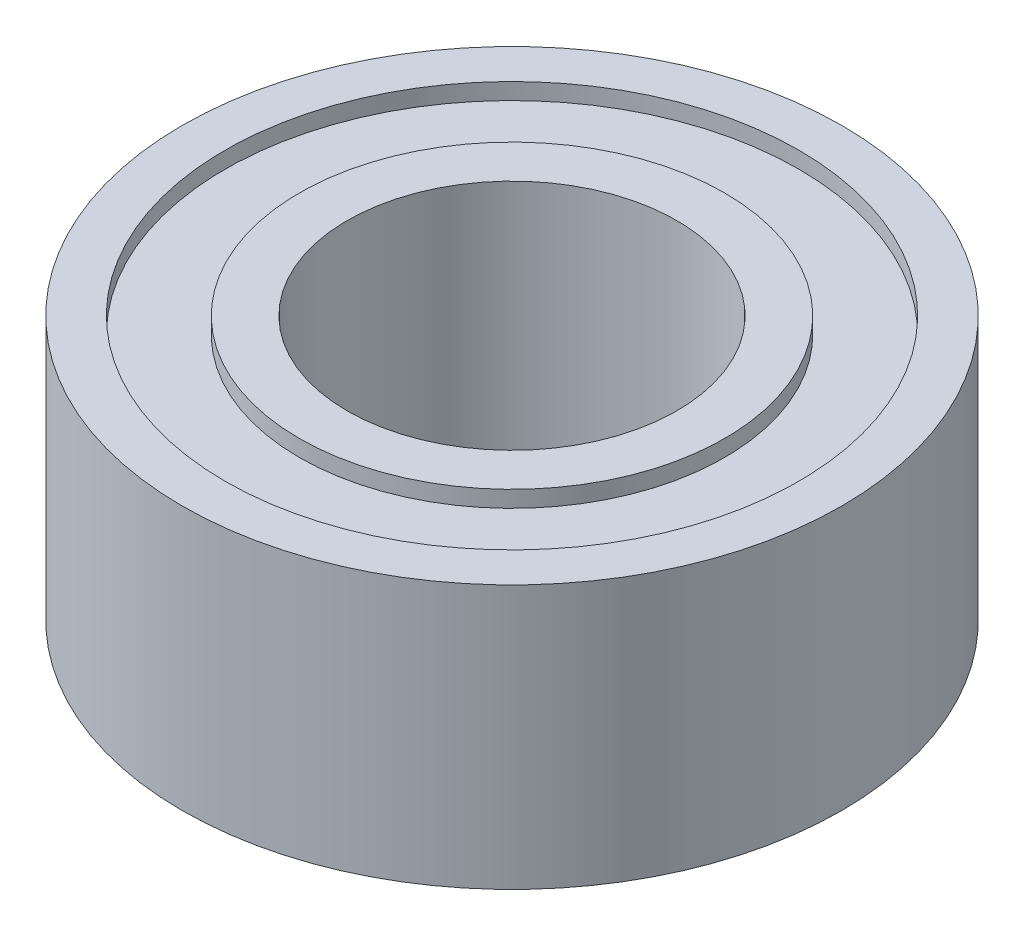
from build123d import *

# Parameters (mm, degrees)
SKETCH1_R           = 5
SKETCH1_R_2         = 2.5
BOSS_EXTRUDE1_DEPTH = 4
SKETCH2_R           = 4.35
SKETCH2_R_2         = 3.225
CUT_EXTRUDE1_DEPTH  = 0.25
SKETCH3_R           = 4.35
SKETCH3_R_2         = 3.225
CUT_EXTRUDE2_DEPTH  = 0.25


with BuildPart() as part:
    # Sketch1 → Boss-Extrude1 (new body)
    with BuildSketch(Plane(origin=(0, 0, 0), x_dir=(1, 0, 0), z_dir=(0, 1, 0))):
        Circle(SKETCH1_R)
        Circle(SKETCH1_R_2, mode=Mode.SUBTRACT)
    extrude(amount=BOSS_EXTRUDE1_DEPTH)

    # Sketch2 → Cut-Extrude1 (cut)
    with BuildSketch(Plane(origin=(0, 4, 0), x_dir=(1, 0, 0), z_dir=(0, 1, 0))):
        Circle(SKETCH2_R)
        Circle(SKETCH2_R_2, mode=Mode.SUBTRACT)
    extrude(amount=-CUT_EXTRUDE1_DEPTH, mode=Mode.SUBTRACT)

    # Sketch3 → Cut-Extrude2 (cut)
    with BuildSketch(Plane.XZ):
        Circle(SKETCH3_R)
        Circle(SKETCH3_R_2, mode=Mode.SUBTRACT)
    extrude(amount=-CUT_EXTRUDE2_DEPTH, mode=Mode.SUBTRACT)


solid = part.part
